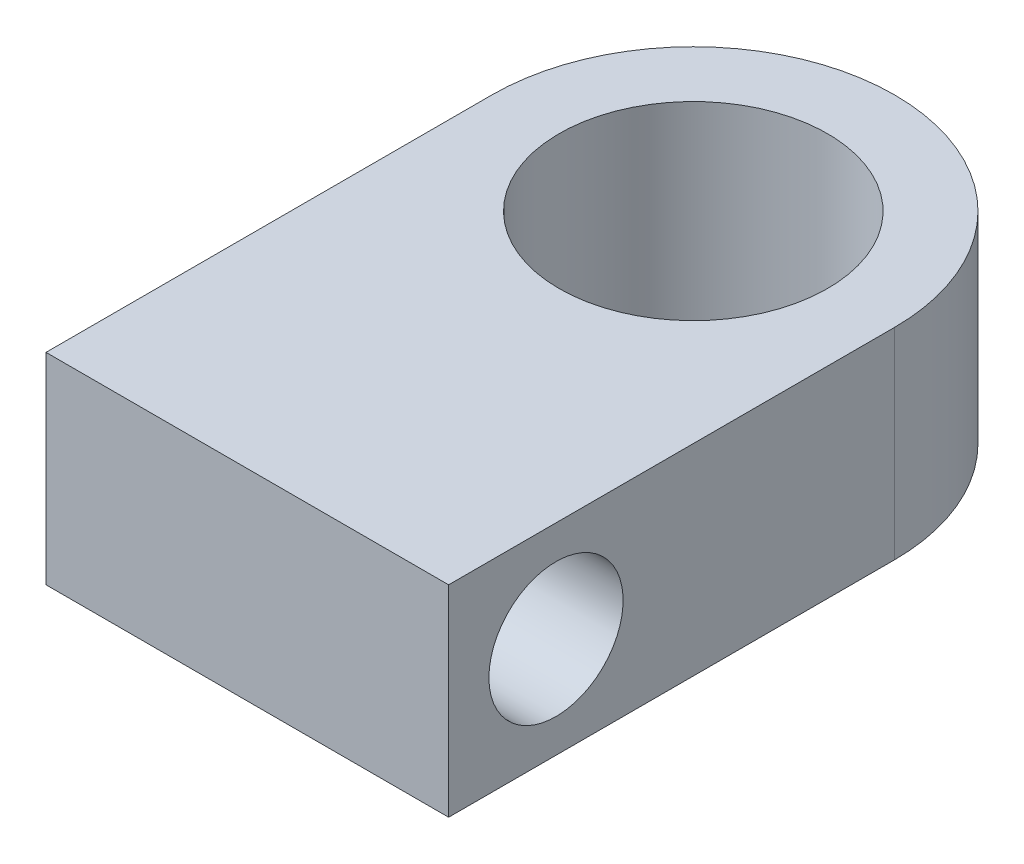
from build123d import *

# Parameters (mm, degrees)
SKETCH1_R           = 9.525
SKETCH1_R_2         = 6.35
BOSS_EXTRUDE1_DEPTH = 9.525
BOSS_EXTRUDE2_DEPTH = 9.525
SKETCH3_R           = 3.175
CUT_EXTRUDE1_DEPTH  = 20.05


with BuildPart() as part:
    # Sketch1 → Boss-Extrude1 (new body)
    with BuildSketch(Plane(origin=(0, 0, 0), x_dir=(1, 0, 0), z_dir=(0, 1, 0))):
        Circle(SKETCH1_R)
        Circle(SKETCH1_R_2, mode=Mode.SUBTRACT)
    extrude(amount=BOSS_EXTRUDE1_DEPTH)

    # Sketch2 → Boss-Extrude2 (add, through all)
    with BuildSketch(Plane(origin=(0, 9.525, 0), x_dir=(1, 0, 0), z_dir=(0, 1, 0))):
        with BuildLine():
            Line((-9.525, 0), (-9.525, -21.100260413))
            Line((-9.525, -21.100260413), (9.525, -21.100260413))
            Line((9.525, -21.100260413), (9.525, 0))
            ThreePointArc((9.525, 0), (0, -9.525), (-9.525, 0))
        make_face()
    extrude(amount=-BOSS_EXTRUDE2_DEPTH)

    # Sketch3 → Cut-Extrude1 (cut, through all)
    with BuildSketch(Plane.ZY.offset(9.525)):
        with Locations((16.020260413, 4.7625)):
            Circle(SKETCH3_R)
    extrude(amount=-CUT_EXTRUDE1_DEPTH, mode=Mode.SUBTRACT)


solid = part.part
